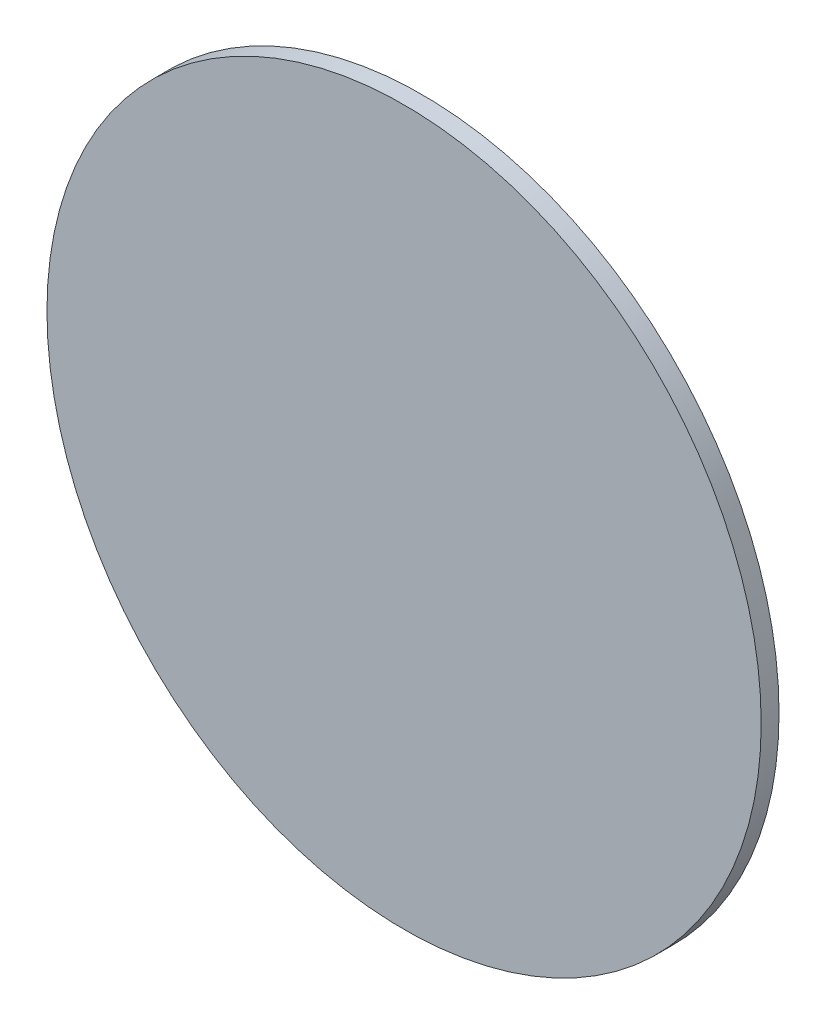
from build123d import *

# Parameters (mm, degrees)
SKETCH1_R           = 60
BOSS_EXTRUDE1_DEPTH = 3


with BuildPart() as part:
    # Sketch1 → Boss-Extrude1 (new body)
    with BuildSketch(Plane.XY):
        Circle(SKETCH1_R)
    extrude(amount=BOSS_EXTRUDE1_DEPTH)


solid = part.part
